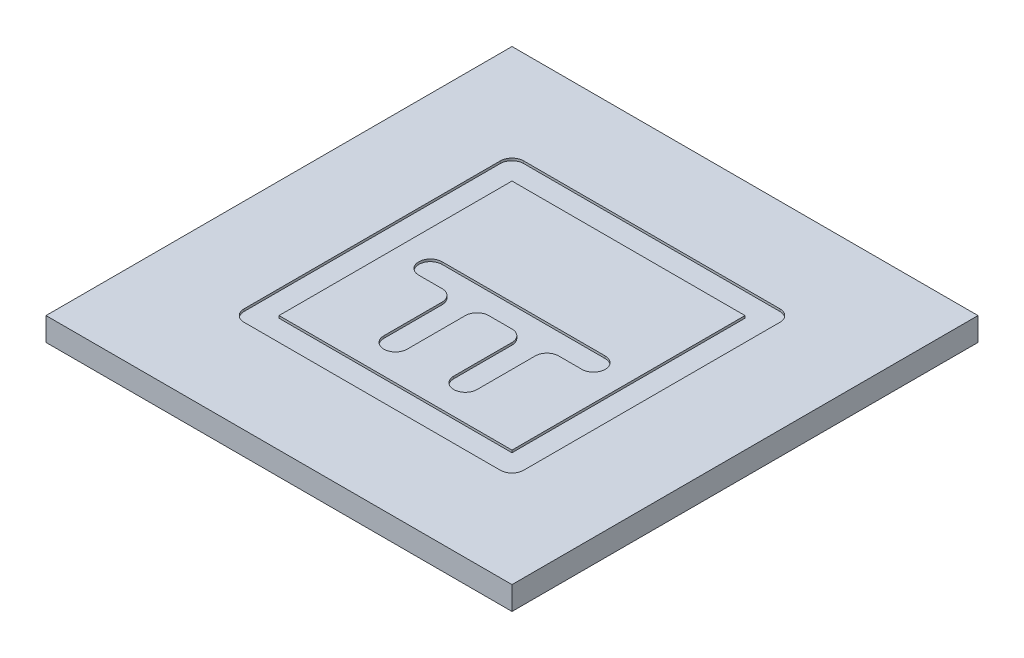
from build123d import *

# Parameters (mm, degrees)
SKETCH1_W           = 200
SKETCH1_H           = 200
BOSS_EXTRUDE1_DEPTH = 10
SKETCH2_W           = 120
SKETCH2_H           = 120
SKETCH2_W_2         = 100
SKETCH2_H_2         = 100
CUT_EXTRUDE1_DEPTH  = 1
FILLET1_R           = 5


with BuildPart() as part:
    # Sketch1 → Boss-Extrude1 (new body)
    with BuildSketch(Plane(origin=(0, 0, 0), x_dir=(1, 0, 0), z_dir=(0, 1, 0))):
        Rectangle(SKETCH1_W, SKETCH1_H)
    extrude(amount=BOSS_EXTRUDE1_DEPTH)

    # Sketch2 → Cut-Extrude1 (cut)
    with BuildSketch(Plane(origin=(0, 10, 0), x_dir=(1, 0, 0), z_dir=(0, 1, 0))):
        Rectangle(SKETCH2_W, SKETCH2_H)
        Rectangle(SKETCH2_W_2, SKETCH2_H_2, mode=Mode.SUBTRACT)
        with BuildLine():
            Line((-35, 5), (35, 5))
            ThreePointArc((35, 5), (40, 0), (35, -5))
            Line((35, -5), (20, -5))
            Line((20, -5), (20, -35))
            ThreePointArc((20, -35), (15, -40), (10, -35))
            Line((10, -35), (10, -5))
            Line((10, -5), (-10, -5))
            Line((-10, -5), (-10, -35))
            ThreePointArc((-10, -35), (-15, -40), (-20, -35))
            Line((-20, -35), (-20, -5))
            Line((-20, -5), (-35, -5))
            ThreePointArc((-35, -5), (-40, 0), (-35, 5))
        make_face()
    extrude(amount=-CUT_EXTRUDE1_DEPTH, mode=Mode.SUBTRACT)

    # Fillet1
    fillet1_edges = [part.edges().sort_by_distance(p)[0] for p in [
        (20, 9.5, 5),
        (10, 9.5, 5),
        (-10, 9.5, 5),
        (-20, 9.5, 5),
        (-60, 9.5, 60),
        (-60, 9.5, -60),
        (60, 9.5, -60),
        (60, 9.5, 60),
    ]]
    fillet(fillet1_edges, radius=FILLET1_R)


solid = part.part
